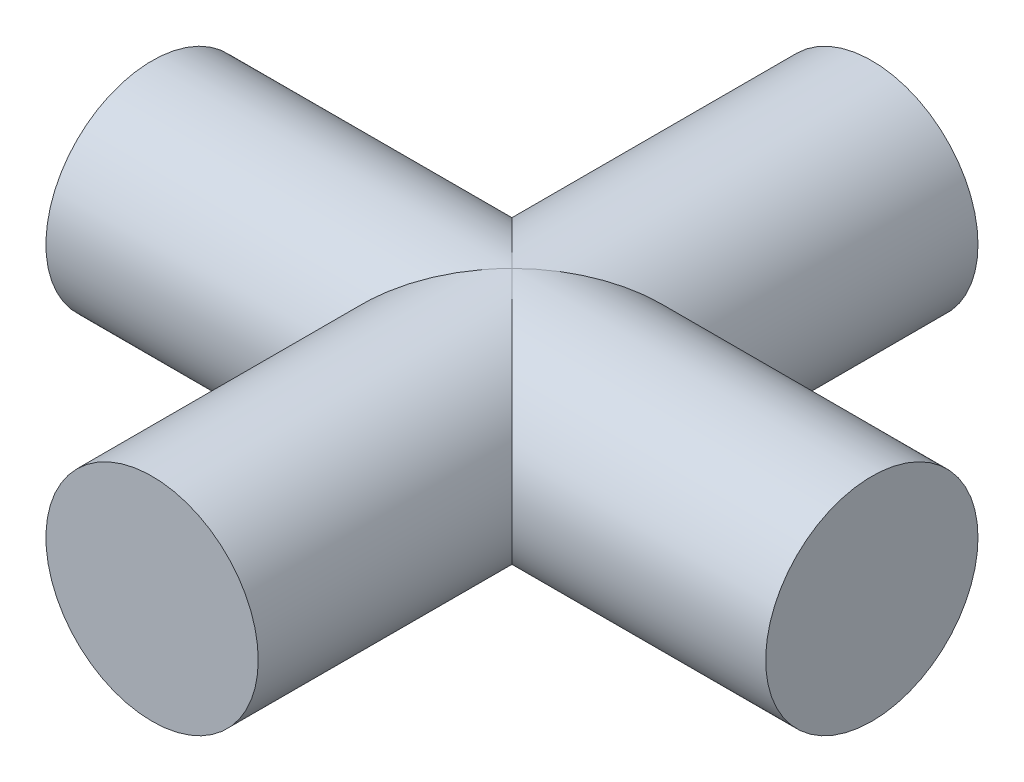
from build123d import *

# Parameters (mm, degrees)
SKETCH1_R           = 1.475
BOSS_EXTRUDE1_DEPTH = 5
SKETCH2_R           = 1.475
BOSS_EXTRUDE2_DEPTH = 5


with BuildPart() as part:
    # Sketch1 → Boss-Extrude1 (new body, symmetric)
    with BuildSketch(Plane.XY):
        Circle(SKETCH1_R)
    extrude(amount=BOSS_EXTRUDE1_DEPTH, both=True)

    # Sketch2 → Boss-Extrude2 (add, symmetric)
    with BuildSketch(Plane(origin=(0, 0, 0), x_dir=(0, 0, -1), z_dir=(1, 0, 0))):
        Circle(SKETCH2_R)
    extrude(amount=BOSS_EXTRUDE2_DEPTH, both=True)


solid = part.part
